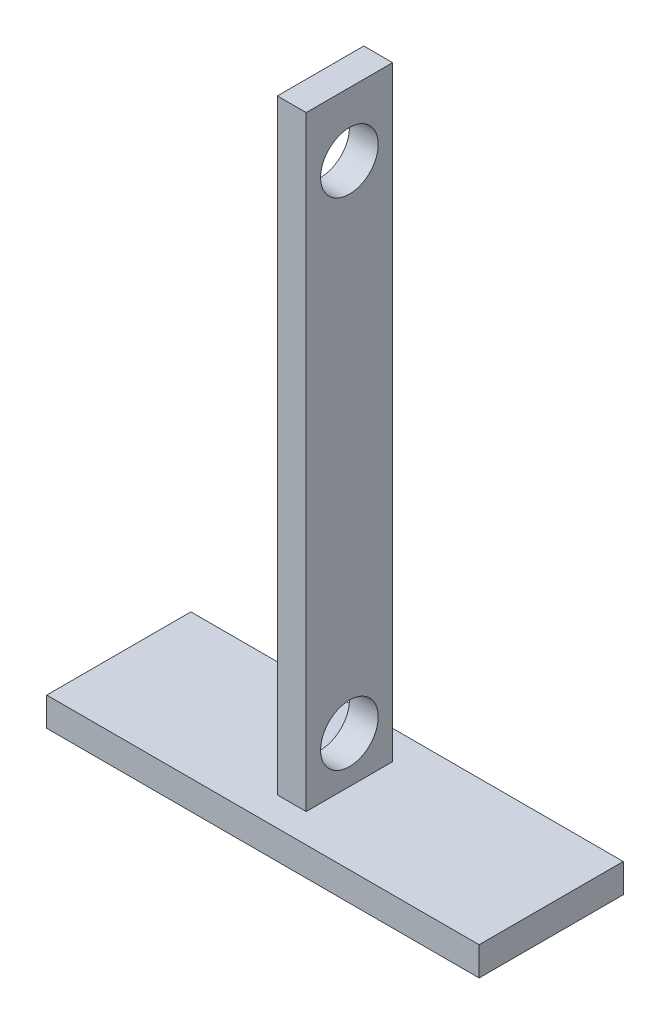
from build123d import *

# Parameters (mm, degrees)
SKETCH1_W           = 75
SKETCH1_H           = 25
BOSS_EXTRUDE1_DEPTH = 5
SKETCH2_W           = 5
SKETCH2_H           = 15
BOSS_EXTRUDE3_DEPTH = 105
SKETCH3_R           = 5
CUT_EXTRUDE1_DEPTH  = 41
SKETCH4_R           = 5
CUT_EXTRUDE2_DEPTH  = 41


with BuildPart() as part:
    # Sketch1 → Boss-Extrude1 (new body)
    with BuildSketch(Plane(origin=(0, 0, 0), x_dir=(1, 0, 0), z_dir=(0, 1, 0))):
        with Locations((84.381711682, 3.75)):
            Rectangle(SKETCH1_W, SKETCH1_H)
    extrude(amount=BOSS_EXTRUDE1_DEPTH)

    # Sketch2 → Boss-Extrude3 (add)
    with BuildSketch(Plane(origin=(0, 5, 0), x_dir=(1, 0, 0), z_dir=(0, 1, 0))):
        with Locations((84.381711682, 3.75)):
            Rectangle(SKETCH2_W, SKETCH2_H)
    extrude(amount=BOSS_EXTRUDE3_DEPTH)

    # Sketch3 → Cut-Extrude1 (cut, through all)
    with BuildSketch(Plane.ZY.offset(-81.881711682)):
        with Locations((-3.75, 13)):
            Circle(SKETCH3_R)
    extrude(amount=-CUT_EXTRUDE1_DEPTH, mode=Mode.SUBTRACT)

    # Sketch4 → Cut-Extrude2 (cut, through all)
    with BuildSketch(Plane.ZY.offset(-81.881711682)):
        with Locations((-3.75, 99)):
            Circle(SKETCH4_R)
    extrude(amount=-CUT_EXTRUDE2_DEPTH, mode=Mode.SUBTRACT)


solid = part.part
